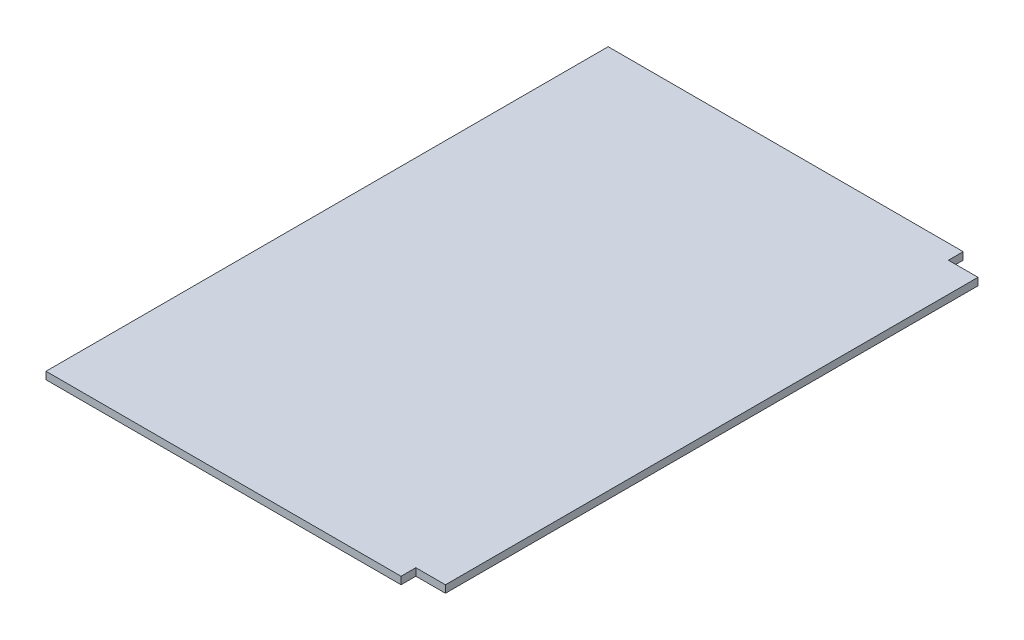
from build123d import *

# Parameters (mm, degrees)
SKETCH3_W           = 914.4
SKETCH3_H           = 1219.2
BOSS_EXTRUDE1_DEPTH = 12.7
SKETCH4_W           = 254
SKETCH4_H           = 965.2
CUT_EXTRUDE1_DEPTH  = 12.7
SKETCH5_W           = 50.8
SKETCH5_H           = 25.4
CUT_EXTRUDE2_DEPTH  = 12.7


with BuildPart() as part:
    # Sketch3 → Boss-Extrude1 (new body)
    with BuildSketch(Plane(origin=(0, 0, 0), x_dir=(1, 0, 0), z_dir=(0, 1, 0))):
        Rectangle(SKETCH3_W, SKETCH3_H)
    extrude(amount=-BOSS_EXTRUDE1_DEPTH)

    # Sketch4 → Cut-Extrude1 (cut)
    with BuildSketch(Plane(origin=(0, 0, 0), x_dir=(1, 0, 0), z_dir=(0, 1, 0))):
        Polygon((-457.2, 609.6), (-457.2, 355.6), (203.2, 355.6), (457.2, 355.6), (457.2, 609.6), align=None)
        with Locations((330.2, -127)):
            Rectangle(SKETCH4_W, SKETCH4_H)
    extrude(amount=-CUT_EXTRUDE1_DEPTH, mode=Mode.SUBTRACT)

    # Sketch5 → Cut-Extrude2 (cut)
    with BuildSketch(Plane(origin=(0, 0, 0), x_dir=(1, 0, 0), z_dir=(0, 1, 0))):
        with Locations((177.8, 342.9)):
            Rectangle(SKETCH5_W, SKETCH5_H)
        with Locations((177.8, -596.9)):
            Rectangle(SKETCH5_W, SKETCH5_H)
    extrude(amount=-CUT_EXTRUDE2_DEPTH, mode=Mode.SUBTRACT)


solid = part.part
